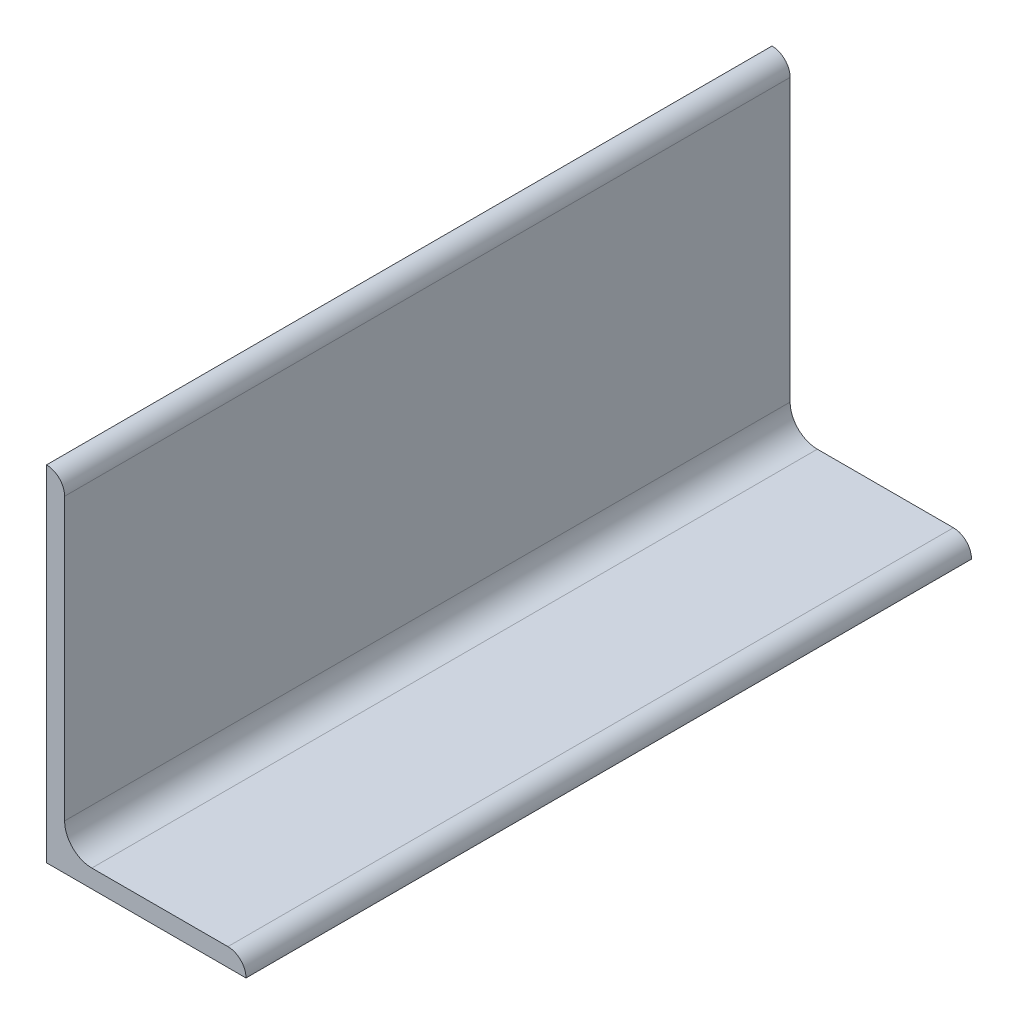
from build123d import *

# Parameters (mm, degrees)
BASESTEELANGLE_DEPTH = 63.5


with BuildPart() as part:
    # Sketch1 → BaseSteelAngle (new body, symmetric)
    with BuildSketch(Plane.XY):
        with BuildLine():
            Line((0, 0), (0, 60.325))
            Line((0, 60.325), (0.00508, 60.325))
            ThreePointArc((0.00508, 60.325), (2.246551928, 59.396551928), (3.175, 57.15508))
            Line((3.175, 57.15508), (3.175, 7.9375))
            ThreePointArc((3.175, 7.9375), (4.569903955, 4.569903955), (7.9375, 3.175))
            Line((7.9375, 3.175), (31.75508, 3.175))
            ThreePointArc((31.75508, 3.175), (33.996551928, 2.246551928), (34.925, 0.00508))
            Line((34.925, 0.00508), (34.925, 0))
            Line((34.925, 0), (0, 0))
        make_face()
    extrude(amount=BASESTEELANGLE_DEPTH, both=True)


solid = part.part
